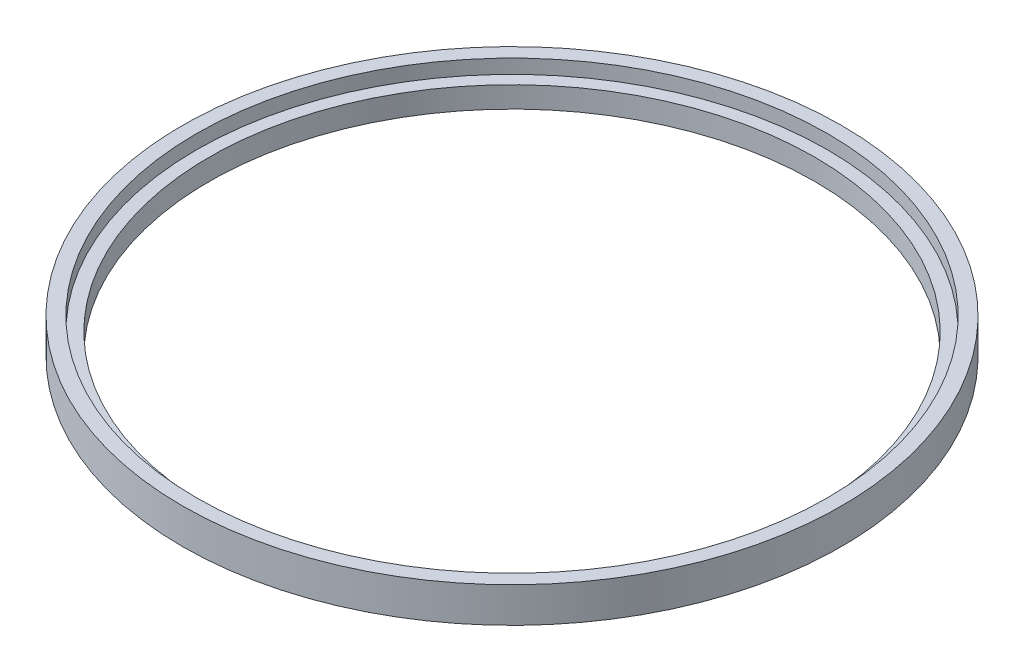
from build123d import *

# Parameters (mm, degrees)
SKETCH1_R           = 23.4
SKETCH1_R_2         = 21.5
BOSS_EXTRUDE1_DEPTH = 1.5
SKETCH2_R           = 23.4
SKETCH2_R_2         = 22.4
BOSS_EXTRUDE2_DEPTH = 1


with BuildPart() as part:
    # Sketch1 → Boss-Extrude1 (new body)
    with BuildSketch(Plane(origin=(0, 0, 0), x_dir=(1, 0, 0), z_dir=(0, 1, 0))):
        Circle(SKETCH1_R)
        Circle(SKETCH1_R_2, mode=Mode.SUBTRACT)
    extrude(amount=BOSS_EXTRUDE1_DEPTH)

    # Sketch2 → Boss-Extrude2 (add)
    with BuildSketch(Plane(origin=(0, 1.5, 0), x_dir=(1, 0, 0), z_dir=(0, 1, 0))):
        Circle(SKETCH2_R)
        Circle(SKETCH2_R_2, mode=Mode.SUBTRACT)
    extrude(amount=BOSS_EXTRUDE2_DEPTH)


solid = part.part
